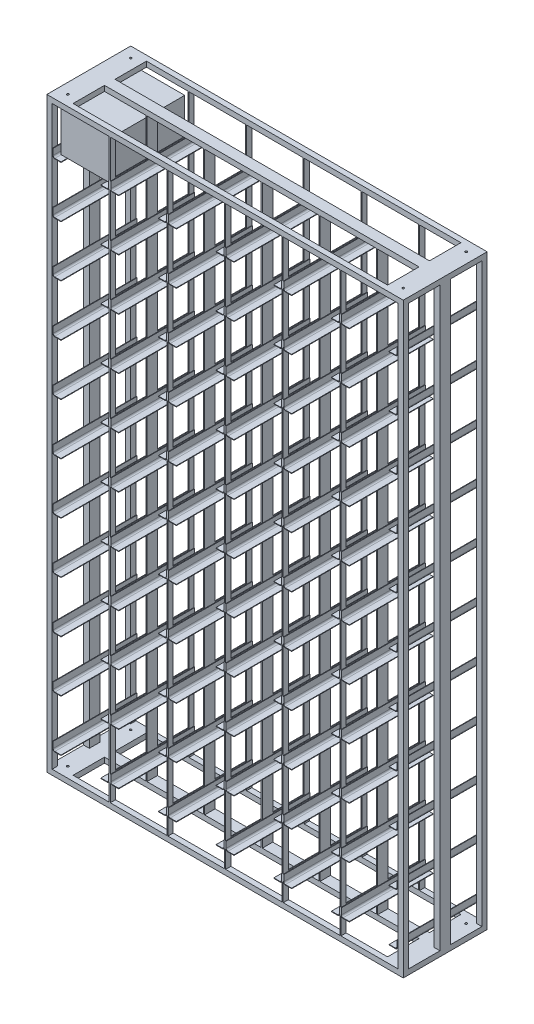
from build123d import *

# Parameters (mm, degrees)
SKETCH1_W                = 25
SKETCH1_H                = 400
SKETCH1_W_2              = 1650
SKETCH1_H_2              = 50
BOSS_EXTRUDE1_DEPTH      = 25
BOSS_EXTRUDE2_DEPTH      = 1375
MIRROR5_COPY_1_DEPTH     = 1375
MIRROR6_COPY_1_DEPTH     = 1375
MIRROR6_COPY_2_DEPTH     = 1375
MIRROR6_COPY_3_DEPTH     = 1375
SKETCH3_W                = 175
SKETCH3_H                = 25
BOSS_EXTRUDE3_DEPTH      = 75
MIRROR8_COPY_1_SKETCH_W  = 175
MIRROR8_COPY_1_SKETCH_H  = 25
MIRROR8_COPY_1_DEPTH     = 75
SKETCH4_R                = 5
CUT_EXTRUDE1_DEPTH       = 26
BOSS_EXTRUDE4_REACH      = 2777
SKETCH5_W                = 25
SKETCH5_H                = 25
BOSS_EXTRUDE5_REACH      = 1602
SKETCH6_W                = 25
SKETCH6_H                = 25
SKETCH7_W                = 50
SKETCH7_H                = 2750
BOSS_EXTRUDE6_DEPTH      = 5
LPATTERN1_COUNT          = 5
LPATTERN1_PITCH          = 275
BOSS_EXTRUDE7_DEPTH      = 200
LPATTERN2_COUNT          = 6
LPATTERN2_PITCH          = 275
LPATTERN2_COUNT_DIR2     = 11
LPATTERN2_PITCH_DIR2     = 245
SKETCH12_W               = 5
SKETCH12_H               = 25
BOSS_EXTRUDE8_DEPTH      = 2750
LPATTERN3_COUNT          = 5
LPATTERN3_PITCH          = 275
SKETCH13_W               = 250
SKETCH13_H               = 200
BOSS_EXTRUDE9_DEPTH      = 170
BOSS_EXTRUDE9_DEPTH_BACK = 170


with BuildPart() as part:
    # Sketch1 → Boss-Extrude1 (new body)
    with BuildSketch(Plane(origin=(0, 0, 0), x_dir=(1, 0, 0), z_dir=(0, 1, 0))):
        with Locations((-837.5, 0)):
            Rectangle(SKETCH1_W, SKETCH1_H)
        Rectangle(SKETCH1_W_2, SKETCH1_H_2)
        with Locations((837.5, 0)):
            Rectangle(SKETCH1_W, SKETCH1_H)
    boss_extrude1 = extrude(amount=BOSS_EXTRUDE1_DEPTH)

    # Sketch2 → Boss-Extrude2 (add)
    with BuildSketch(Plane(origin=(0, 25, 0), x_dir=(1, 0, 0), z_dir=(0, 1, 0))):
        Polygon((-822.5, 25), (-850, 25), (-850, 0), (-850, -25), (-822.5, -25), (-822.5, -2.5), align=None)
    boss_extrude2 = extrude(amount=BOSS_EXTRUDE2_DEPTH)

    # Mirror1: Boss-Extrude2 across plane
    add(boss_extrude2.mirror(Plane(origin=(0, 0, 0), x_dir=(0, 0, 1), z_dir=(1, 0, 0))))

    # Mirror5: Boss-Extrude2 across plane
    add(boss_extrude2.mirror(Plane.ZX.offset(1400)))

    # Mirror5 copy 1 sketch → Mirror5 copy 1 (add)
    with BuildSketch(Plane(origin=(0, 2775, 0), x_dir=(-1, 0, 0), z_dir=(0, -1, 0))):
        Polygon((-822.5, 25), (-850, 25), (-850, 0), (-850, -25), (-822.5, -25), (-822.5, -2.5), align=None)
    extrude(amount=MIRROR5_COPY_1_DEPTH)

    # Mirror6: Boss-Extrude1 across plane
    add(boss_extrude1.mirror(Plane.ZX.offset(1400)))

    # Mirror6 copy 1 sketch → Mirror6 copy 1 (add)
    with BuildSketch(Plane(origin=(0, 25, 0), x_dir=(1, 0, 0), z_dir=(0, 1, 0))):
        Polygon((-822.5, 25), (-850, 25), (-850, 0), (-850, -25), (-822.5, -25), (-822.5, -2.5), align=None)
    extrude(amount=MIRROR6_COPY_1_DEPTH)

    # Mirror6 copy 2 sketch → Mirror6 copy 2 (add)
    with BuildSketch(Plane(origin=(0, 25, 0), x_dir=(-1, 0, 0), z_dir=(0, 1, 0))):
        Polygon((-822.5, -25), (-850, -25), (-850, 0), (-850, 25), (-822.5, 25), (-822.5, 2.5), align=None)
    extrude(amount=MIRROR6_COPY_2_DEPTH)

    # Mirror6 copy 3 sketch → Mirror6 copy 3 (add)
    with BuildSketch(Plane.XZ.offset(-2775)):
        Polygon((-822.5, -25), (-850, -25), (-850, 0), (-850, 25), (-822.5, 25), (-822.5, 2.5), align=None)
    extrude(amount=MIRROR6_COPY_3_DEPTH)

    # Sketch3 → Boss-Extrude3 (add)
    with BuildSketch(Plane(origin=(-825, 0, 0), x_dir=(0, 0, -1), z_dir=(1, 0, 0))):
        with Locations((-112.5, 12.5)):
            Rectangle(SKETCH3_W, SKETCH3_H)
        with Locations((112.5, 12.5)):
            Rectangle(SKETCH3_W, SKETCH3_H)
    boss_extrude3 = extrude(amount=BOSS_EXTRUDE3_DEPTH)

    # Mirror7: Boss-Extrude3 across plane
    add(boss_extrude3.mirror(Plane(origin=(0, 0, 0), x_dir=(0, 0, 1), z_dir=(1, 0, 0))))

    # Mirror8: Boss-Extrude3 across plane
    add(boss_extrude3.mirror(Plane.ZX.offset(1400)))

    # Mirror8 copy 1 sketch → Mirror8 copy 1 (add)
    with BuildSketch(Plane(origin=(825, 2800, 0), x_dir=(0, 0, -1), z_dir=(-1, 0, 0))):
        with Locations((-112.5, 12.5)):
            Rectangle(MIRROR8_COPY_1_SKETCH_W, MIRROR8_COPY_1_SKETCH_H)
        with Locations((112.5, 12.5)):
            Rectangle(MIRROR8_COPY_1_SKETCH_W, MIRROR8_COPY_1_SKETCH_H)
    extrude(amount=MIRROR8_COPY_1_DEPTH)

    # Sketch4 → Cut-Extrude1 (cut, through all)
    with BuildSketch(Plane(origin=(0, 25, 0), x_dir=(1, 0, 0), z_dir=(0, 1, 0))):
        with Locations((-800, -150)):
            Circle(SKETCH4_R)
        with Locations((-800, 150)):
            Circle(SKETCH4_R)
        with Locations((800, 150)):
            Circle(SKETCH4_R)
        with Locations((800, -150)):
            Circle(SKETCH4_R)
    cut_extrude1 = extrude(amount=-CUT_EXTRUDE1_DEPTH, mode=Mode.SUBTRACT)

    # Mirror9: Cut-Extrude1 across plane
    add(cut_extrude1.mirror(Plane.ZX.offset(1400)), mode=Mode.SUBTRACT)

    # Sketch5 → Boss-Extrude4 (add, up to next)
    with BuildSketch(Plane(origin=(0, 25, 0), x_dir=(1, 0, 0), z_dir=(0, 1, 0)), mode=Mode.PRIVATE) as boss_extrude4_sk1:
        with Locations((-837.5, -187.5)):
            Rectangle(SKETCH5_W, SKETCH5_H)
    boss_extrude4_tool1 = extrude(boss_extrude4_sk1.sketch, amount=BOSS_EXTRUDE4_REACH, mode=Mode.PRIVATE) - part.part
    add(boss_extrude4_tool1.solids().sort_by_distance((-837.5, 25, 187.5))[0])
    # Sketch5 → Boss-Extrude4 (add, up to next)
    with BuildSketch(Plane(origin=(0, 25, 0), x_dir=(1, 0, 0), z_dir=(0, 1, 0)), mode=Mode.PRIVATE) as boss_extrude4_sk2:
        with Locations((-837.5, 187.5)):
            Rectangle(SKETCH5_W, SKETCH5_H)
    boss_extrude4_tool2 = extrude(boss_extrude4_sk2.sketch, amount=BOSS_EXTRUDE4_REACH, mode=Mode.PRIVATE) - part.part
    add(boss_extrude4_tool2.solids().sort_by_distance((-837.5, 25, -187.5))[0])
    # Sketch5 → Boss-Extrude4 (add, up to next)
    with BuildSketch(Plane(origin=(0, 25, 0), x_dir=(1, 0, 0), z_dir=(0, 1, 0)), mode=Mode.PRIVATE) as boss_extrude4_sk3:
        with Locations((837.5, -187.5)):
            Rectangle(SKETCH5_W, SKETCH5_H)
    boss_extrude4_tool3 = extrude(boss_extrude4_sk3.sketch, amount=BOSS_EXTRUDE4_REACH, mode=Mode.PRIVATE) - part.part
    add(boss_extrude4_tool3.solids().sort_by_distance((837.5, 25, 187.5))[0])
    # Sketch5 → Boss-Extrude4 (add, up to next)
    with BuildSketch(Plane(origin=(0, 25, 0), x_dir=(1, 0, 0), z_dir=(0, 1, 0)), mode=Mode.PRIVATE) as boss_extrude4_sk4:
        with Locations((837.5, 187.5)):
            Rectangle(SKETCH5_W, SKETCH5_H)
    boss_extrude4_tool4 = extrude(boss_extrude4_sk4.sketch, amount=BOSS_EXTRUDE4_REACH, mode=Mode.PRIVATE) - part.part
    add(boss_extrude4_tool4.solids().sort_by_distance((837.5, 25, -187.5))[0])

    # Sketch6 → Boss-Extrude5 (add, up to next)
    with BuildSketch(Plane(origin=(-750, 0, 0), x_dir=(0, 0, -1), z_dir=(1, 0, 0)), mode=Mode.PRIVATE) as boss_extrude5_sk1:
        with Locations((-187.5, 2787.5)):
            Rectangle(SKETCH6_W, SKETCH6_H)
    boss_extrude5_tool1 = extrude(boss_extrude5_sk1.sketch, amount=BOSS_EXTRUDE5_REACH, mode=Mode.PRIVATE) - part.part
    add(boss_extrude5_tool1.solids().sort_by_distance((-750, 2787.5, 187.5))[0])
    # Sketch6 → Boss-Extrude5 (add, up to next)
    with BuildSketch(Plane(origin=(-750, 0, 0), x_dir=(0, 0, -1), z_dir=(1, 0, 0)), mode=Mode.PRIVATE) as boss_extrude5_sk2:
        with Locations((187.5, 2787.5)):
            Rectangle(SKETCH6_W, SKETCH6_H)
    boss_extrude5_tool2 = extrude(boss_extrude5_sk2.sketch, amount=BOSS_EXTRUDE5_REACH, mode=Mode.PRIVATE) - part.part
    add(boss_extrude5_tool2.solids().sort_by_distance((-750, 2787.5, -187.5))[0])
    # Sketch6 → Boss-Extrude5 (add, up to next)
    with BuildSketch(Plane(origin=(-750, 0, 0), x_dir=(0, 0, -1), z_dir=(1, 0, 0)), mode=Mode.PRIVATE) as boss_extrude5_sk3:
        with Locations((187.5, 12.5)):
            Rectangle(SKETCH6_W, SKETCH6_H)
    boss_extrude5_tool3 = extrude(boss_extrude5_sk3.sketch, amount=BOSS_EXTRUDE5_REACH, mode=Mode.PRIVATE) - part.part
    add(boss_extrude5_tool3.solids().sort_by_distance((-750, 12.5, -187.5))[0])
    # Sketch6 → Boss-Extrude5 (add, up to next)
    with BuildSketch(Plane(origin=(-750, 0, 0), x_dir=(0, 0, -1), z_dir=(1, 0, 0)), mode=Mode.PRIVATE) as boss_extrude5_sk4:
        with Locations((-187.5, 12.5)):
            Rectangle(SKETCH6_W, SKETCH6_H)
    boss_extrude5_tool4 = extrude(boss_extrude5_sk4.sketch, amount=BOSS_EXTRUDE5_REACH, mode=Mode.PRIVATE) - part.part
    add(boss_extrude5_tool4.solids().sort_by_distance((-750, 12.5, 187.5))[0])

    # Sketch7 → Boss-Extrude6 (add)
    with BuildSketch(Plane(origin=(-552.5, 0, 0), x_dir=(0, 0, -1), z_dir=(1, 0, 0))):
        with Locations((0, 1400)):
            Rectangle(SKETCH7_W, SKETCH7_H)
    boss_extrude6 = extrude(amount=BOSS_EXTRUDE6_DEPTH)

    # LPattern1: Boss-Extrude6 ×5
    with Locations(*[(i * LPATTERN1_PITCH, 0, 0) for i in range(1, LPATTERN1_COUNT)]):
        add(boss_extrude6)

    # Sketch9 → Boss-Extrude7 (add, symmetric)
    with BuildSketch(Plane.XY):
        with BuildLine():
            Line((-822.5, 2592.5), (-820, 2592.5))
            Line((-820, 2592.5), (-820, 2563))
            ThreePointArc((-820, 2563), (-817.656854249, 2557.343145751), (-812, 2555))
            Line((-812, 2555), (-782.5, 2555))
            Line((-782.5, 2555), (-782.5, 2552.5))
            Line((-782.5, 2552.5), (-812, 2552.5))
            ThreePointArc((-812, 2552.5), (-819.424621202, 2555.575378798), (-822.5, 2563))
            Line((-822.5, 2563), (-822.5, 2592.5))
        make_face()
        with BuildLine():
            Line((-592.5, 2552.5), (-563, 2552.5))
            ThreePointArc((-563, 2552.5), (-555.575378798, 2555.575378798), (-552.5, 2563))
            Line((-552.5, 2563), (-552.5, 2592.5))
            Line((-552.5, 2592.5), (-555, 2592.5))
            Line((-555, 2592.5), (-555, 2563.5))
            ThreePointArc((-555, 2563.5), (-557.48959236, 2557.48959236), (-563.5, 2555))
            Line((-563.5, 2555), (-592.5, 2555))
            Line((-592.5, 2555), (-592.5, 2552.5))
        make_face()
    boss_extrude7 = extrude(amount=BOSS_EXTRUDE7_DEPTH, both=True)

    # LPattern2: Boss-Extrude7 6 × 11
    with Locations(*[(i * LPATTERN2_PITCH, -j * LPATTERN2_PITCH_DIR2, 0) for i in range(LPATTERN2_COUNT) for j in range(LPATTERN2_COUNT_DIR2) if (i, j) != (0, 0)]):
        add(boss_extrude7)

    # Sketch12 → Boss-Extrude8 (add)
    with BuildSketch(Plane(origin=(0, 25, 0), x_dir=(1, 0, 0), z_dir=(0, 1, 0))):
        with Locations((-550, -187.5)):
            Rectangle(SKETCH12_W, SKETCH12_H)
        with Locations((-550, 187.5)):
            Rectangle(SKETCH12_W, SKETCH12_H)
    boss_extrude8 = extrude(amount=BOSS_EXTRUDE8_DEPTH)

    # LPattern3: Boss-Extrude8 ×5
    with Locations(*[(i * LPATTERN3_PITCH, 0, 0) for i in range(1, LPATTERN3_COUNT)]):
        add(boss_extrude8)

    # Sketch13 → Boss-Extrude9 (add, two sides)
    with BuildSketch(Plane.XY) as boss_extrude9_sk:
        with Locations((-687.5, 2655)):
            Rectangle(SKETCH13_W, SKETCH13_H)
    extrude(amount=BOSS_EXTRUDE9_DEPTH)
    extrude(boss_extrude9_sk.sketch, amount=-BOSS_EXTRUDE9_DEPTH_BACK)


solid = part.part
